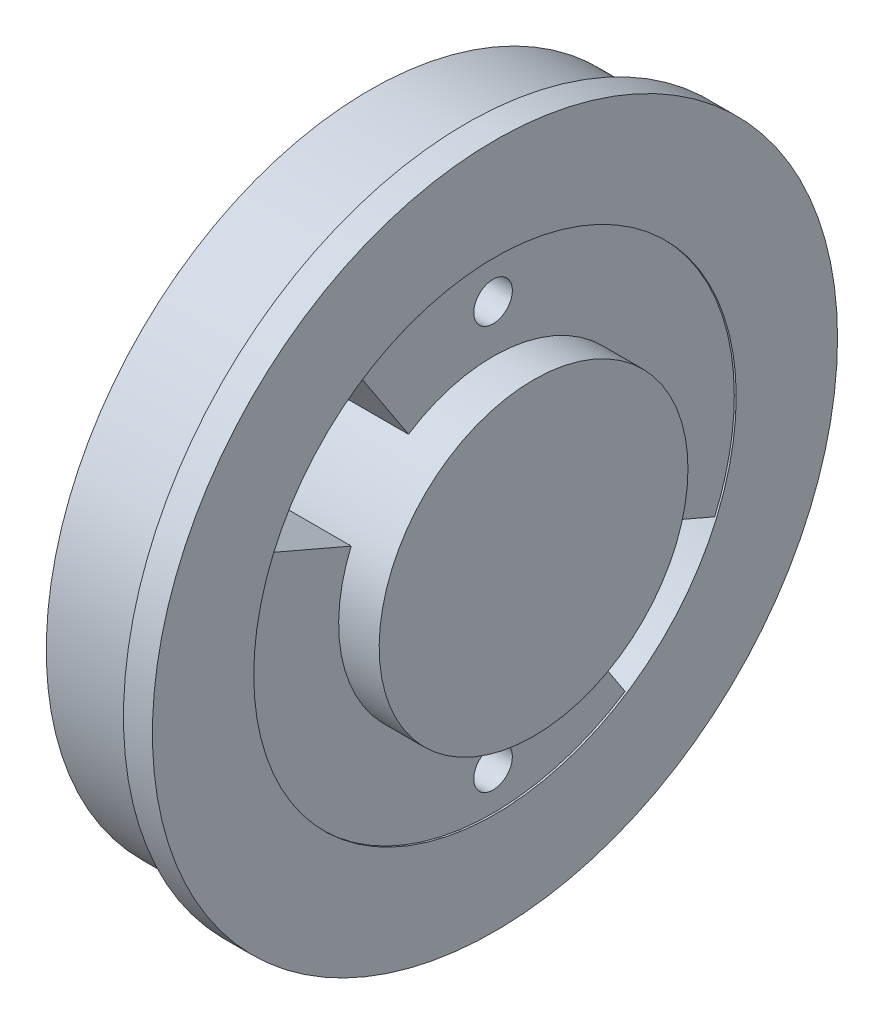
from build123d import *

# Parameters (mm, degrees)
SKETCH1_R          = 16.75
EXTRUDE1_DEPTH     = 5
SKETCH2_R          = 17.75
EXTRUDE2_DEPTH     = 1.5
SKETCH3_R          = 8
EXTRUDE3_DEPTH     = 2
SKETCH4_R          = 12.5
SKETCH4_R_2        = 8
CUT_EXTRUDE1_DEPTH = 0.1
SKETCH5_R          = 1
CUT_EXTRUDE2_DEPTH = 30.1
SKETCH6_R          = 14.75
CUT_EXTRUDE3_DEPTH = 3


with BuildPart() as part:
    # Sketch1 → Extrude1 (new body)
    with BuildSketch(Plane(origin=(0, 0, 0), x_dir=(0, 0, -1), z_dir=(1, 0, 0))):
        Circle(SKETCH1_R)
    extrude(amount=EXTRUDE1_DEPTH)

    # Sketch2 → Extrude2 (add)
    with BuildSketch(Plane(origin=(5, 0, 0), x_dir=(0, 0, -1), z_dir=(1, 0, 0))):
        Circle(SKETCH2_R)
    extrude(amount=EXTRUDE2_DEPTH)

    # Sketch3 → Extrude3 (add)
    with BuildSketch(Plane(origin=(6.5, 0, 0), x_dir=(0, 0, -1), z_dir=(1, 0, 0))):
        Circle(SKETCH3_R)
    extrude(amount=EXTRUDE3_DEPTH)

    # Sketch4 → Cut-Extrude1 (cut)
    with BuildSketch(Plane(origin=(6.5, 0, 0), x_dir=(0, 0, -1), z_dir=(1, 0, 0))):
        Circle(SKETCH4_R)
        Circle(SKETCH4_R_2, mode=Mode.SUBTRACT)
    extrude(amount=-CUT_EXTRUDE1_DEPTH, mode=Mode.SUBTRACT)

    # Sketch5 → Cut-Extrude2 (cut)
    with BuildSketch(Plane(origin=(8.5, 0, 0), x_dir=(0, 0, -1), z_dir=(1, 0, 0))):
        with Locations((0, 10.459544408)):
            Circle(SKETCH5_R)
        with Locations((0, -10.459544408)):
            Circle(SKETCH5_R)
        with BuildLine():
            Line((-11.482295218, 4.940333646), (-7.348668939, 3.161813533))
            ThreePointArc((-7.348668939, 3.161813533), (-6.12476255, 5.146579807), (-4.380515089, 6.694108421))
            Line((-4.380515089, 6.694108421), (-6.844554827, 10.459544408))
            ThreePointArc((-6.844554827, 10.459544408), (-9.569941484, 8.041530949), (-11.482295218, 4.940333646))
        make_face()
        with BuildLine():
            Line((6.844554827, -10.459544408), (4.380515089, -6.694108421))
            ThreePointArc((4.380515089, -6.694108421), (6.12476255, -5.146579807), (7.348668939, -3.161813533))
            Line((7.348668939, -3.161813533), (11.482295218, -4.940333646))
            ThreePointArc((11.482295218, -4.940333646), (9.569941484, -8.041530949), (6.844554827, -10.459544408))
        make_face()
    extrude(amount=-CUT_EXTRUDE2_DEPTH, mode=Mode.SUBTRACT)

    # Sketch6 → Cut-Extrude3 (cut)
    with BuildSketch(Plane.ZY):
        Circle(SKETCH6_R)
    extrude(amount=-CUT_EXTRUDE3_DEPTH, mode=Mode.SUBTRACT)


solid = part.part
